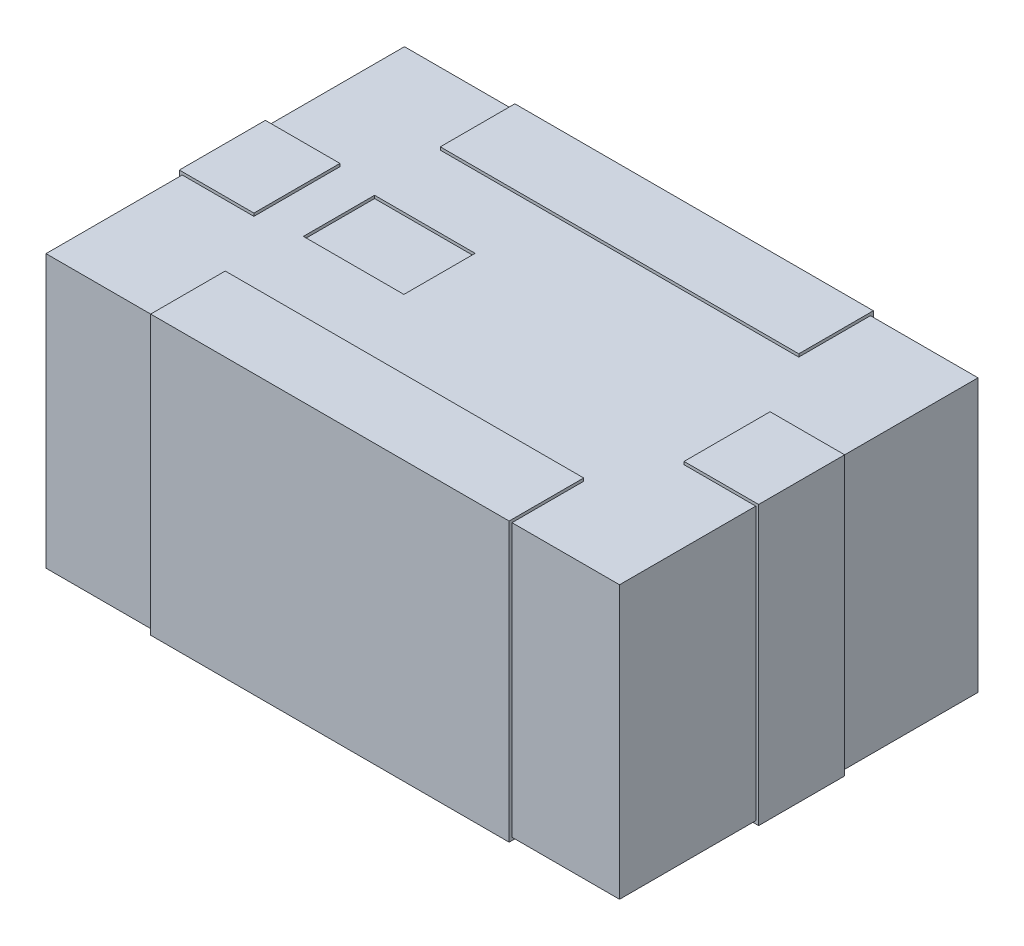
from build123d import *

# Parameters (mm, degrees)
SKETCH1_W           = 2
SKETCH1_H           = 1.25
BOSS_EXTRUDE1_DEPTH = 0.475
SKETCH2_W           = 0.26
SKETCH2_H           = 0.3
SKETCH2_W_2         = 1.25
SKETCH2_H_2         = 0.26
BOSS_EXTRUDE2_DEPTH = 0.485
SKETCH3_W           = 0.350615202
SKETCH3_H           = 0.248352434
CUT_EXTRUDE1_DEPTH  = 0.01


with BuildPart() as part:
    # Sketch1 → Boss-Extrude1 (new body, symmetric)
    with BuildSketch(Plane(origin=(0, 0, 0), x_dir=(1, 0, 0), z_dir=(0, 1, 0))):
        Rectangle(SKETCH1_W, SKETCH1_H)
    extrude(amount=BOSS_EXTRUDE1_DEPTH, both=True)

    # Sketch2 → Boss-Extrude2 (add, symmetric)
    with BuildSketch(Plane(origin=(0, 0, 0), x_dir=(1, 0, 0), z_dir=(0, 1, 0))):
        with Locations((-0.88, 0)):
            Rectangle(SKETCH2_W, SKETCH2_H)
        with Locations((0, 0.505)):
            Rectangle(SKETCH2_W_2, SKETCH2_H_2)
        with Locations((0, -0.505)):
            Rectangle(SKETCH2_W_2, SKETCH2_H_2)
        with Locations((0.88, 0)):
            Rectangle(SKETCH2_W, SKETCH2_H)
    extrude(amount=BOSS_EXTRUDE2_DEPTH, both=True)

    # Sketch3 → Cut-Extrude1 (cut)
    with BuildSketch(Plane(origin=(0, 0.475, 0), x_dir=(1, 0, 0), z_dir=(0, 1, 0))):
        with Locations((-0.428042726, 0)):
            Rectangle(SKETCH3_W, SKETCH3_H)
    extrude(amount=-CUT_EXTRUDE1_DEPTH, mode=Mode.SUBTRACT)


solid = part.part
